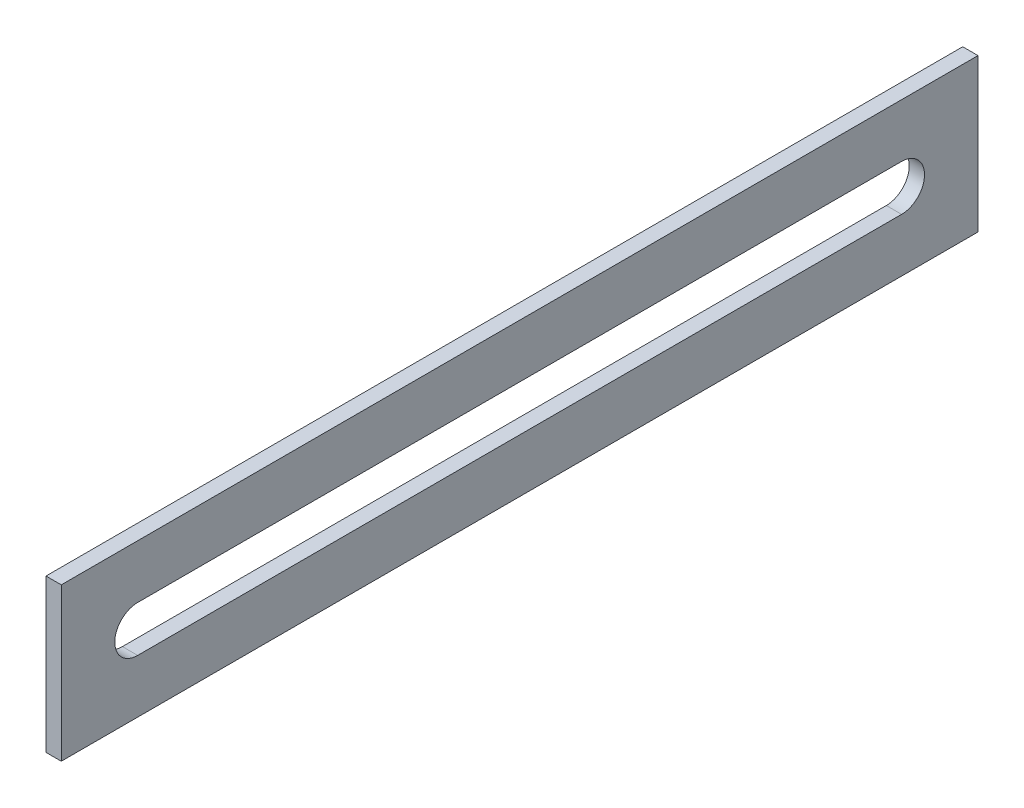
from build123d import *

# Parameters (mm, degrees)
SKETCH_1_W      = 60
SKETCH_1_H      = 10
EXTRUDE_1_DEPTH = 1


with BuildPart() as part:
    # 草图1 → 凸台-拉伸1 (new body)
    with BuildSketch(Plane(origin=(0, 0, 0), x_dir=(0, 0, -1), z_dir=(1, 0, 0))):
        with Locations((28.433962264, 4.621952123)):
            Rectangle(SKETCH_1_W, SKETCH_1_H)
        with BuildLine():
            Line((3.433962264, 6.121952123), (53.433962264, 6.121952123))
            ThreePointArc((53.433962264, 6.121952123), (54.933962264, 4.621952123), (53.433962264, 3.121952123))
            Line((53.433962264, 3.121952123), (3.433962264, 3.121952123))
            ThreePointArc((3.433962264, 3.121952123), (1.933962264, 4.621952123), (3.433962264, 6.121952123))
        make_face(mode=Mode.SUBTRACT)
    extrude(amount=EXTRUDE_1_DEPTH)


solid = part.part
